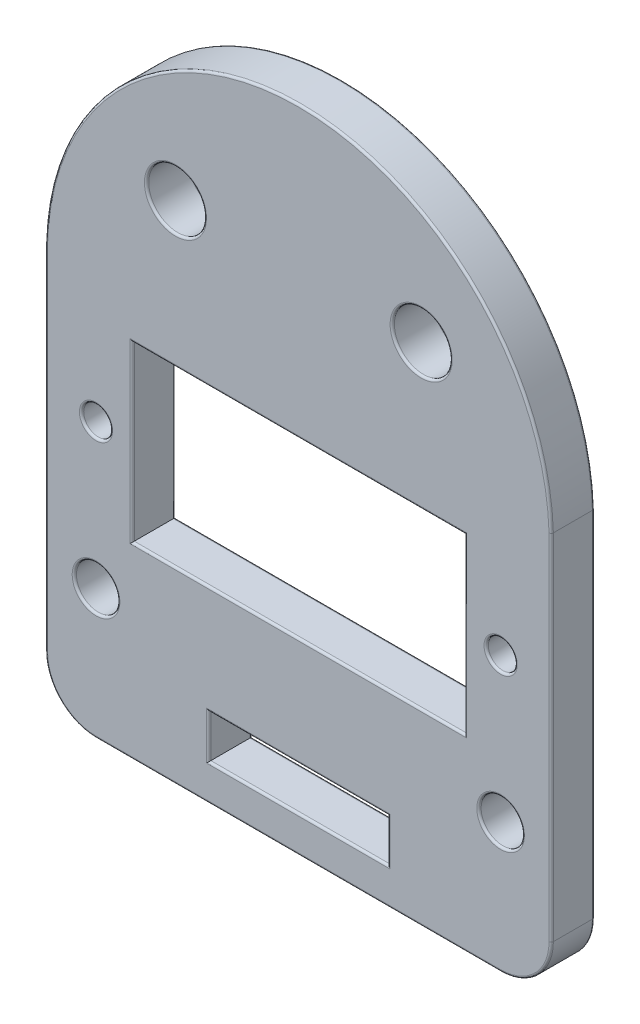
from build123d import *

# Parameters (mm, degrees)
SKETCH1_R           = 1
SKETCH1_R_2         = 1.5
SKETCH1_R_3         = 2
SKETCH1_W           = 23
SKETCH1_H           = 12
SKETCH1_W_2         = 12.4
SKETCH1_H_2         = 3
BOSS_EXTRUDE1_DEPTH = 3
FILLET1_R           = 3.5
FILLET2_R           = 0.15


with BuildPart() as part:
    # Sketch1 → Boss-Extrude1 (new body)
    with BuildSketch(Plane.XY):
        with BuildLine():
            Line((-17.5, 9), (-17.5, -19))
            Line((-17.5, -19), (17.5, -19))
            Line((17.5, -19), (17.5, 9))
            ThreePointArc((17.5, 9), (0, 26), (-17.5, 9))
        make_face()
        with Locations((-14, 0)):
            Circle(SKETCH1_R, mode=Mode.SUBTRACT)
        with Locations((-14, -10)):
            Circle(SKETCH1_R_2, mode=Mode.SUBTRACT)
        with Locations((-8.5, 16)):
            Circle(SKETCH1_R_3, mode=Mode.SUBTRACT)
        with Locations((14, -10)):
            Circle(SKETCH1_R_2, mode=Mode.SUBTRACT)
        with Locations((14, 0)):
            Circle(SKETCH1_R, mode=Mode.SUBTRACT)
        with Locations((8.5, 16)):
            Circle(SKETCH1_R_3, mode=Mode.SUBTRACT)
        Rectangle(SKETCH1_W, SKETCH1_H, mode=Mode.SUBTRACT)
        with Locations((0, -15)):
            Rectangle(SKETCH1_W_2, SKETCH1_H_2, mode=Mode.SUBTRACT)
    extrude(amount=BOSS_EXTRUDE1_DEPTH)

    # Fillet1
    fillet1_edges = [part.edges().sort_by_distance(p)[0] for p in [
        (17.5, -19, 1.5),
        (-17.5, -19, 1.5),
    ]]
    fillet(fillet1_edges, radius=FILLET1_R)

    # Fillet2
    fillet2_edges = [part.edges().sort_by_distance(p)[0] for p in [
        (-11.5, 0, 0),
        (0, -6, 0),
        (11.5, 0, 0),
        (0, 6, 0),
        (-11.5, 0, 3),
        (0, -6, 3),
        (11.5, 0, 3),
        (0, 6, 3),
        (-15, 0, 0),
        (-15, 0, 3),
        (-15.5, -10, 0),
        (-15.5, -10, 3),
        (-6.2, -15, 0),
        (0, -16.5, 0),
        (6.2, -15, 0),
        (0, -13.5, 0),
        (-6.2, -15, 3),
        (0, -16.5, 3),
        (6.2, -15, 3),
        (0, -13.5, 3),
        (0, 26, 3),
        (-10.5, 16, 0),
        (-10.5, 16, 3),
        (12.5, -10, 0),
        (12.5, -10, 3),
        (-17.5, -3.25, 0),
        (13, 0, 0),
        (13, 0, 3),
        (0, 26, 0),
        (6.5, 16, 0),
        (6.5, 16, 3),
        (17.5, -3.25, 0),
        (17.5, -3.25, 3),
        (0, -19, 0),
        (-17.5, -3.25, 3),
        (-16.474873734, -17.974873734, 0),
        (16.474873734, -17.974873734, 0),
        (0, -19, 3),
        (-16.474873734, -17.974873734, 3),
        (16.474873734, -17.974873734, 3),
    ]]
    fillet(fillet2_edges, radius=FILLET2_R)


solid = part.part
